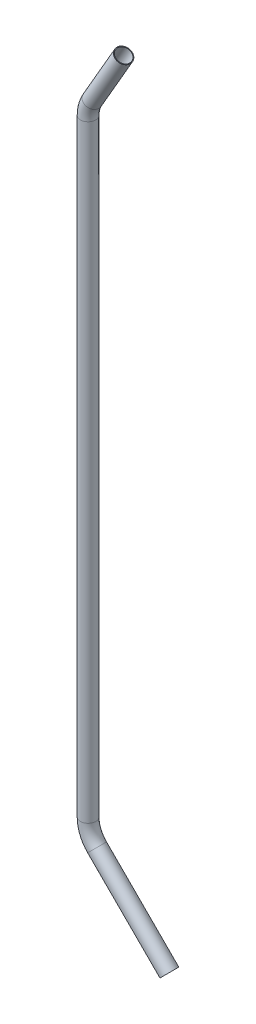
from build123d import *

# Parameters (mm, degrees)
SKETCH2_R   = 9.525
SKETCH2_R_2 = 8.7122


with BuildPart() as part:
    # Sweep1: sweep along a path in Sketch1
    with BuildLine(Plane.XY) as sweep1_path:
        Line((-11.159231637, -185.328818363), (-100.600768363, -95.887281637))
        ThreePointArc((-100.600768363, -95.887281637), (-108.859810189, -83.526752047), (-111.76, -68.946513274))
        Line((-111.76, -68.946513274), (-111.76, 682.844622495))
        ThreePointArc((-111.76, 682.844622495), (-110.461773982, 692.705628113), (-106.655567884, 701.894622495))
        Line((-106.655567884, 701.894622495), (-67.765909488, 769.253486726))
    # Sketch2 → Sweep1 (sweep)
    with BuildSketch(Plane(origin=(0, 0, 0), x_dir=(1, 0, 0), z_dir=(0, 1, 0))):
        with Locations((-111.76, 0)):
            Circle(SKETCH2_R)
        with Locations((-111.76, 0)):
            Circle(SKETCH2_R_2, mode=Mode.SUBTRACT)
    sweep(path=sweep1_path.line)


solid = part.part
